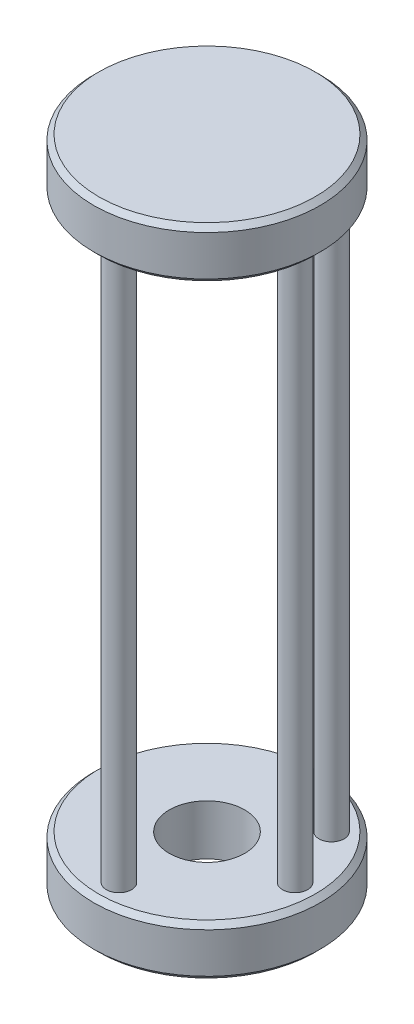
from build123d import *

# Parameters (mm, degrees)
SKETCH1_R           = 45
BOSS_EXTRUDE1_DEPTH = 20
SKETCH2_R           = 15
CUT_EXTRUDE1_DEPTH  = 21
SKETCH3_R           = 5
BOSS_EXTRUDE2_DEPTH = 220
SKETCH4_R           = 45
BOSS_EXTRUDE3_DEPTH = 20
CHAMFER1_SIZE       = 2


with BuildPart() as part:
    # Sketch1 → Boss-Extrude1 (new body)
    with BuildSketch(Plane(origin=(0, 0, 0), x_dir=(1, 0, 0), z_dir=(0, 1, 0))):
        Circle(SKETCH1_R)
    extrude(amount=BOSS_EXTRUDE1_DEPTH)

    # Sketch2 → Cut-Extrude1 (cut, through all)
    with BuildSketch(Plane(origin=(0, 20, 0), x_dir=(1, 0, 0), z_dir=(0, 1, 0))):
        Circle(SKETCH2_R)
    extrude(amount=-CUT_EXTRUDE1_DEPTH, mode=Mode.SUBTRACT)

    # Sketch3 → Boss-Extrude2 (add)
    with BuildSketch(Plane(origin=(0, 20, 0), x_dir=(1, 0, 0), z_dir=(0, 1, 0))):
        with Locations((35, 0)):
            Circle(SKETCH3_R)
        with Locations((0, -35)):
            Circle(SKETCH3_R)
        with Locations((-35, 0)):
            Circle(SKETCH3_R)
        with Locations((0, 35)):
            Circle(SKETCH3_R)
        with Locations((24.748737342, 24.748737342)):
            Circle(SKETCH3_R)
    extrude(amount=BOSS_EXTRUDE2_DEPTH)

    # Sketch4 → Boss-Extrude3 (add)
    with BuildSketch(Plane(origin=(0, 240, 0), x_dir=(1, 0, 0), z_dir=(0, 1, 0))):
        Circle(SKETCH4_R)
    extrude(amount=BOSS_EXTRUDE3_DEPTH)

    # Chamfer1
    chamfer1_edges = [part.edges().sort_by_distance(p)[0] for p in [
        (-45, 0, 0),
        (-45, 240, 0),
        (-45, 260, 0),
        (-45, 20, 0),
    ]]
    chamfer(chamfer1_edges, length=CHAMFER1_SIZE)


solid = part.part
